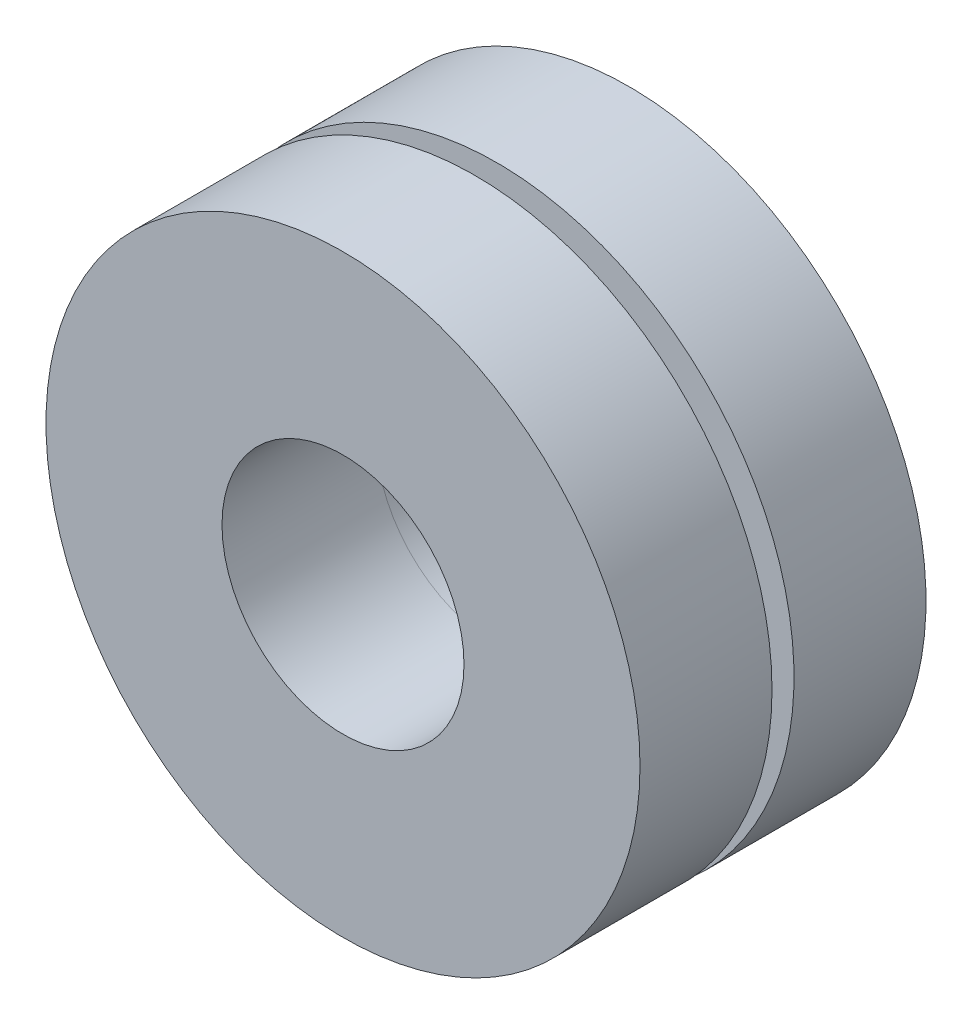
from build123d import *

# Parameters (mm, degrees)
SKETCH1_R           = 6.096
SKETCH1_R_2         = 2.794
BOSS_EXTRUDE2_DEPTH = 0.508
SKETCH3_R           = 6.858
SKETCH3_R_2         = 2.794
BOSS_EXTRUDE3_DEPTH = 3.048
SKETCH4_R           = 6.858
SKETCH4_R_2         = 2.794
BOSS_EXTRUDE4_DEPTH = 3.048


with BuildPart() as part:
    # Sketch1 → Boss-Extrude2 (new body)
    with BuildSketch(Plane.XY):
        Circle(SKETCH1_R)
        Circle(SKETCH1_R_2, mode=Mode.SUBTRACT)
    extrude(amount=BOSS_EXTRUDE2_DEPTH)

    # Sketch3 → Boss-Extrude3 (add)
    with BuildSketch(Plane.XY.offset(0.508)):
        Circle(SKETCH3_R)
        Circle(SKETCH3_R_2, mode=Mode.SUBTRACT)
    extrude(amount=BOSS_EXTRUDE3_DEPTH)


with BuildPart() as body_2:
    # Sketch4 → Boss-Extrude4 (new body)
    with BuildSketch(Plane(origin=(0, 0, 0), x_dir=(-1, 0, 0), z_dir=(0, 0, -1))):
        Circle(SKETCH4_R)
        Circle(SKETCH4_R_2, mode=Mode.SUBTRACT)
    extrude(amount=BOSS_EXTRUDE4_DEPTH)


solid = Compound([part.part, body_2.part])
